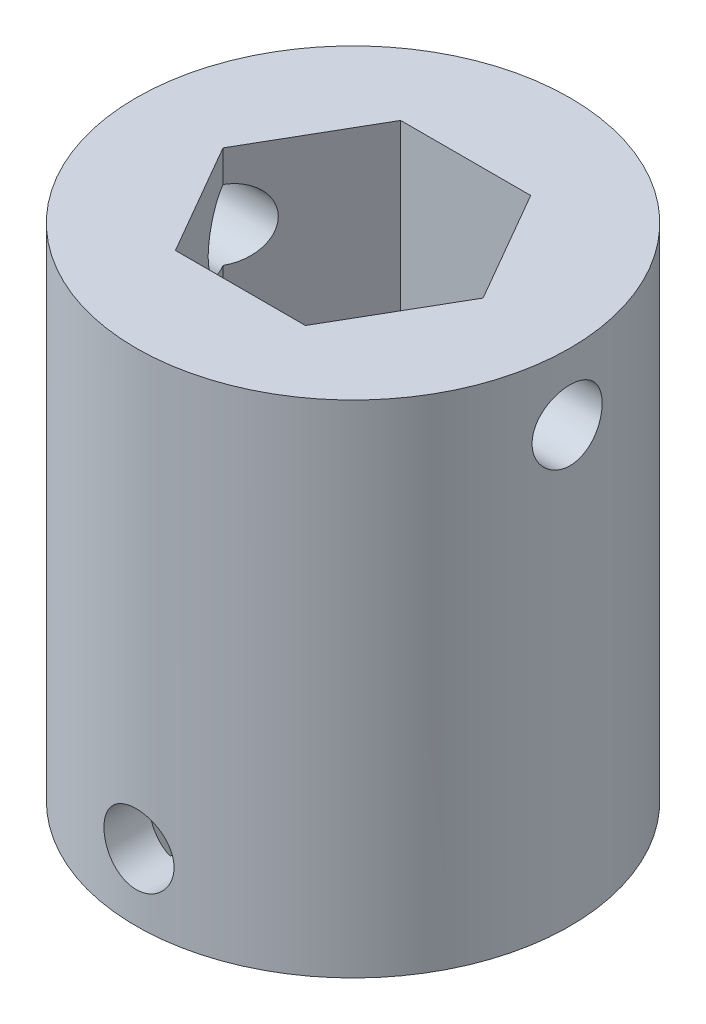
from build123d import *

# Parameters (mm, degrees)
SKETCH1_R               = 13
BOSS_EXTRUDE1_DEPTH     = 15
SKETCH2_R               = 13
BOSS_EXTRUDE2_DEPTH     = 15
CUT_EXTRUDE1_DEPTH      = 15
SKETCH4_R               = 2.1
CUT_EXTRUDE2_DEPTH      = 14
CUT_EXTRUDE2_DEPTH_BACK = 14
SKETCH5_R               = 2.1
CUT_EXTRUDE3_DEPTH      = 14.0000001
CUT_EXTRUDE3_DEPTH_BACK = 14.0000001


with BuildPart() as part:
    # Sketch1 → Boss-Extrude1 (new body)
    with BuildSketch(Plane(origin=(0, 0, 0), x_dir=(1, 0, 0), z_dir=(0, 1, 0))):
        Circle(SKETCH1_R)
        Polygon((7.794228634, 0), (3.897114317, 6.75), (-3.897114317, 6.75), (-7.794228634, 0), (-3.897114317, -6.75), (3.897114317, -6.75), align=None, mode=Mode.SUBTRACT)
    extrude(amount=BOSS_EXTRUDE1_DEPTH)

    # Sketch2 → Boss-Extrude2 (add)
    with BuildSketch(Plane.XZ):
        Circle(SKETCH2_R)
    extrude(amount=BOSS_EXTRUDE2_DEPTH)

    # Sketch3 → Cut-Extrude1 (cut)
    with BuildSketch(Plane.XZ.offset(15)):
        with BuildLine():
            ThreePointArc((-6.243810885, 8.267068745), (-5.854092687, 6.785901876), (-5.214210168, 5.394396961))
            ThreePointArc((-5.214210168, 5.394396961), (-5.398189483, 5.210283731), (-5.575671687, 5.01989955))
            ThreePointArc((-5.575671687, 5.01989955), (-6.988964837, 5.610101244), (-8.483004255, 5.947120212))
            ThreePointArc((-8.483004255, 5.947120212), (-8.868301959, 5.35563445), (-9.212425923, 4.739283555))
            ThreePointArc((-9.212425923, 4.739283555), (-8.21864774, 3.573890707), (-7.038382156, 2.597822718))
            ThreePointArc((-7.038382156, 2.597822718), (-7.124258054, 2.352116797), (-7.201559394, 2.103579935))
            ThreePointArc((-7.201559394, 2.103579935), (-8.730971441, 2.022128371), (-10.223281494, 1.67753256))
            ThreePointArc((-10.223281494, 1.67753256), (-10.313786677, 0.977447894), (-10.356407024, 0.272825133))
            ThreePointArc((-10.356407024, 0.272825133), (-8.955398813, -0.345973348), (-7.468516238, -0.713282174))
            ThreePointArc((-7.468516238, -0.713282174), (-7.439279945, -0.971915715), (-7.401089942, -1.229379485))
            ThreePointArc((-7.401089942, -1.229379485), (-8.743702074, -1.966351826), (-9.938712454, -2.924310989))
            ThreePointArc((-9.938712454, -2.924310989), (-9.716499453, -3.594334206), (-9.449174701, -4.247669652))
            ThreePointArc((-9.449174701, -4.247669652), (-7.918423321, -4.197313138), (-6.419419083, -3.883112783))
            ThreePointArc((-6.419419083, -3.883112783), (-6.280861205, -4.1034484), (-6.134743859, -4.318845221))
            ThreePointArc((-6.134743859, -4.318845221), (-7.024635276, -5.565371928), (-7.685659521, -6.946958883))
            ThreePointArc((-7.685659521, -6.946958883), (-7.194740347, -7.454214334), (-6.670417442, -7.926861368))
            ThreePointArc((-6.670417442, -7.926861368), (-5.313106976, -7.217323584), (-4.09887725, -6.283845283))
            ThreePointArc((-4.09887725, -6.283845283), (-3.878440875, -6.422242804), (-3.653336516, -6.552910693))
            ThreePointArc((-3.653336516, -6.552910693), (-3.91425331, -8.062101865), (-3.910367462, -9.593676371))
            ThreePointArc((-3.910367462, -9.593676371), (-3.247974678, -9.837695893), (-2.570502201, -10.036040974))
            ThreePointArc((-2.570502201, -10.036040974), (-1.655464634, -8.80785458), (-0.966502508, -7.439985158))
            ThreePointArc((-0.966502508, -7.439985158), (-0.707847763, -7.469033257), (-0.448341071, -7.489091836))
            ThreePointArc((-0.448341071, -7.489091836), (-0.028605471, -8.962033652), (0.63942083, -10.340248595))
            ThreePointArc((0.63942083, -10.340248595), (1.34209221, -10.27270113), (2.038532526, -10.157459581))
            ThreePointArc((2.038532526, -10.157459581), (2.330062781, -8.653881955), (2.357299909, -7.122544727))
            ThreePointArc((2.357299909, -7.122544727), (2.60294328, -7.036490072), (2.845453821, -6.941966494))
            ThreePointArc((2.845453821, -6.941966494), (3.862708032, -8.086924763), (5.062563985, -9.03880777))
            ThreePointArc((5.062563985, -9.03880777), (5.666341276, -8.673071921), (6.243810885, -8.267068745))
            ThreePointArc((6.243810885, -8.267068745), (5.854092687, -6.785901876), (5.214210168, -5.394396961))
            ThreePointArc((5.214210168, -5.394396961), (5.398189483, -5.210283731), (5.575671687, -5.01989955))
            ThreePointArc((5.575671687, -5.01989955), (6.988964837, -5.610101244), (8.483004255, -5.947120212))
            ThreePointArc((8.483004255, -5.947120212), (8.868301959, -5.35563445), (9.212425923, -4.739283555))
            ThreePointArc((9.212425923, -4.739283555), (8.21864774, -3.573890707), (7.038382156, -2.597822718))
            ThreePointArc((7.038382156, -2.597822718), (7.124258054, -2.352116797), (7.201559394, -2.103579935))
            ThreePointArc((7.201559394, -2.103579935), (8.730971441, -2.022128371), (10.223281494, -1.67753256))
            ThreePointArc((10.223281494, -1.67753256), (10.313786677, -0.977447894), (10.356407024, -0.272825133))
            ThreePointArc((10.356407024, -0.272825133), (8.955398813, 0.345973348), (7.468516238, 0.713282174))
            ThreePointArc((7.468516238, 0.713282174), (7.439279945, 0.971915715), (7.401089942, 1.229379485))
            ThreePointArc((7.401089942, 1.229379485), (8.743702074, 1.966351826), (9.938712454, 2.924310989))
            ThreePointArc((9.938712454, 2.924310989), (9.716499453, 3.594334206), (9.449174701, 4.247669652))
            ThreePointArc((9.449174701, 4.247669652), (7.918423321, 4.197313138), (6.419419083, 3.883112783))
            ThreePointArc((6.419419083, 3.883112783), (6.280861205, 4.1034484), (6.134743859, 4.318845221))
            ThreePointArc((6.134743859, 4.318845221), (7.024635276, 5.565371928), (7.685659521, 6.946958883))
            ThreePointArc((7.685659521, 6.946958883), (7.194740347, 7.454214334), (6.670417442, 7.926861368))
            ThreePointArc((6.670417442, 7.926861368), (5.313106976, 7.217323584), (4.09887725, 6.283845283))
            ThreePointArc((4.09887725, 6.283845283), (3.878440875, 6.422242804), (3.653336516, 6.552910693))
            ThreePointArc((3.653336516, 6.552910693), (3.91425331, 8.062101865), (3.910367462, 9.593676371))
            ThreePointArc((3.910367462, 9.593676371), (3.247974678, 9.837695893), (2.570502201, 10.036040974))
            ThreePointArc((2.570502201, 10.036040974), (1.655464634, 8.80785458), (0.966502508, 7.439985158))
            ThreePointArc((0.966502508, 7.439985158), (0.707847763, 7.469033257), (0.448341071, 7.489091836))
            ThreePointArc((0.448341071, 7.489091836), (0.028605471, 8.962033652), (-0.63942083, 10.340248595))
            ThreePointArc((-0.63942083, 10.340248595), (-1.34209221, 10.27270113), (-2.038532526, 10.157459581))
            ThreePointArc((-2.038532526, 10.157459581), (-2.330062781, 8.653881955), (-2.357299909, 7.122544727))
            ThreePointArc((-2.357299909, 7.122544727), (-2.60294328, 7.036490072), (-2.845453821, 6.941966494))
            ThreePointArc((-2.845453821, 6.941966494), (-3.862708032, 8.086924763), (-5.062563985, 9.03880777))
            ThreePointArc((-5.062563985, 9.03880777), (-5.666341276, 8.673071921), (-6.243810885, 8.267068745))
        make_face()
    extrude(amount=-CUT_EXTRUDE1_DEPTH, mode=Mode.SUBTRACT)

    # Sketch4 → Cut-Extrude2 (cut, two sides)
    with BuildSketch(Plane.XY) as cut_extrude2_sk:
        with Locations((0, -11)):
            Circle(SKETCH4_R)
    extrude(amount=CUT_EXTRUDE2_DEPTH, mode=Mode.SUBTRACT)
    extrude(cut_extrude2_sk.sketch, amount=-CUT_EXTRUDE2_DEPTH_BACK, mode=Mode.SUBTRACT)

    # Sketch5 → Cut-Extrude3 (cut, two sides)
    with BuildSketch(Plane(origin=(0, 0, 0), x_dir=(0, 0, -1), z_dir=(1, 0, 0))) as cut_extrude3_sk:
        with Locations((0, 11)):
            Circle(SKETCH5_R)
    extrude(amount=CUT_EXTRUDE3_DEPTH, mode=Mode.SUBTRACT)
    extrude(cut_extrude3_sk.sketch, amount=-CUT_EXTRUDE3_DEPTH_BACK, mode=Mode.SUBTRACT)


solid = part.part
